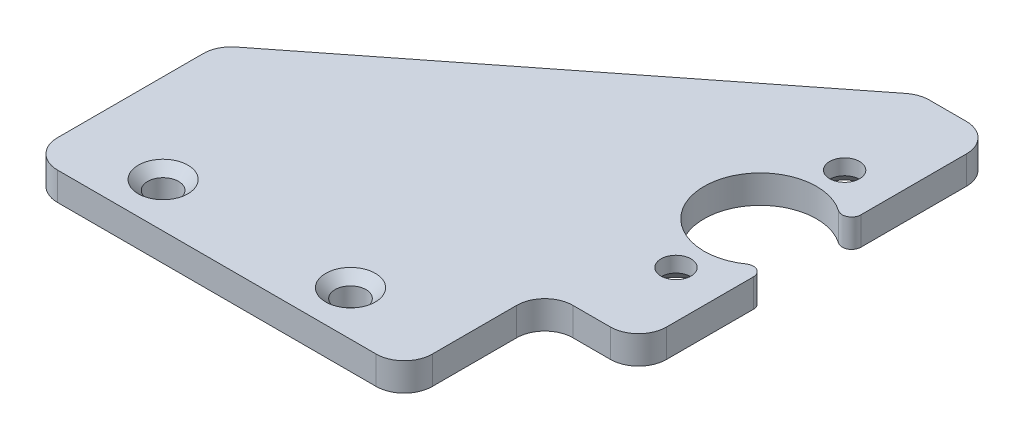
from build123d import *

# Parameters (mm, degrees)
ESBO_O1_R                 = 1.6
RESSALTO_EXTRUS_O10_DEPTH = 3
FILETE2_R                 = 1
CHANFRO1_SIZE             = 1.35
ESBO_O5_W                 = 50
ESBO_O5_H                 = 13
RESSALTO_EXTRUS_O13_DEPTH = 3
ESBO_O7_R                 = 1.65
CORTE_EXTRUS_O1_DEPTH     = 4
ESBO_O8_W                 = 10
ESBO_O8_H                 = 15
CORTE_EXTRUS_O2_DEPTH     = 4
FILETE3_R                 = 3
CHANFRO2_SIZE             = 1
ESBO_O9_R                 = 4
RESSALTO_EXTRUS_O14_DEPTH = 8


with BuildPart() as part:
    # Esboço1 → Ressalto-extrusão10 (new body)
    with BuildSketch(Plane(origin=(0, 0, 0), x_dir=(1, 0, 0), z_dir=(0, 1, 0))):
        with BuildLine():
            Line((25, 20), (-25, 20))
            Line((-25, 20), (-25, -20))
            Line((-25, -20), (25, -20))
            Line((25, -20), (25, -3.31662479))
            ThreePointArc((25, -3.31662479), (14, 0), (25, 3.31662479))
            Line((25, 3.31662479), (25, 20))
        make_face()
        with Locations((20, -9)):
            Circle(ESBO_O1_R, mode=Mode.SUBTRACT)
        with Locations((20, 9)):
            Circle(ESBO_O1_R, mode=Mode.SUBTRACT)
    extrude(amount=RESSALTO_EXTRUS_O10_DEPTH)

    # Filete2
    filete2_edges = [part.edges().sort_by_distance(p)[0] for p in [
        (25, 1.5, 3.31662479),
        (25, 1.5, -3.31662479),
    ]]
    fillet(filete2_edges, radius=FILETE2_R)

    # Chanfro1
    chanfro1_edges = [part.edges().sort_by_distance(p)[0] for p in [
        (18.4, 0, -9),
        (18.4, 0, 9),
    ]]
    chamfer(chanfro1_edges, length=CHANFRO1_SIZE)

    # Esboço5 → Ressalto-extrusão13 (add)
    with BuildSketch(Plane.XZ):
        with Locations((0, 26.5)):
            Rectangle(ESBO_O5_W, ESBO_O5_H)
    extrude(amount=-RESSALTO_EXTRUS_O13_DEPTH)

    # Esboço7 → Corte-extrusão1 (cut, through all)
    with BuildSketch(Plane.XZ):
        with Locations((-15.5, 28.234562647)):
            Circle(ESBO_O7_R)
        with Locations((4.5, 28.234562647)):
            Circle(ESBO_O7_R)
    extrude(amount=-CORTE_EXTRUS_O1_DEPTH, mode=Mode.SUBTRACT)

    # Esboço8 → Corte-extrusão2 (cut, through all)
    with BuildSketch(Plane.XZ):
        Polygon((-25, -20), (-25, 13), (17, -20), align=None)
        with Locations((20, 25.5)):
            Rectangle(ESBO_O8_W, ESBO_O8_H)
    extrude(amount=-CORTE_EXTRUS_O2_DEPTH, mode=Mode.SUBTRACT)

    # Filete3
    filete3_edges = [part.edges().sort_by_distance(p)[0] for p in [
        (25, 1.5, -20),
        (-25, 1.5, 33),
        (-25, 1.5, 13),
        (17, 1.5, -20),
        (15, 1.5, 18),
        (15, 1.5, 33),
        (25, 1.5, 18),
    ]]
    fillet(filete3_edges, radius=FILETE3_R)

    # Chanfro2
    chanfro2_edges = [part.edges().sort_by_distance(p)[0] for p in [
        (-17.15, 3, 28.234562647),
        (2.85, 3, 28.234562647),
    ]]
    chamfer(chanfro2_edges, length=CHANFRO2_SIZE)

    # Esboço9 → Ressalto-extrusão14 (add)
    with BuildSketch(Plane.XZ):
        with Locations((-5.5, 10.234562647)):
            Circle(ESBO_O9_R)
    extrude(amount=RESSALTO_EXTRUS_O14_DEPTH)


solid = part.part
